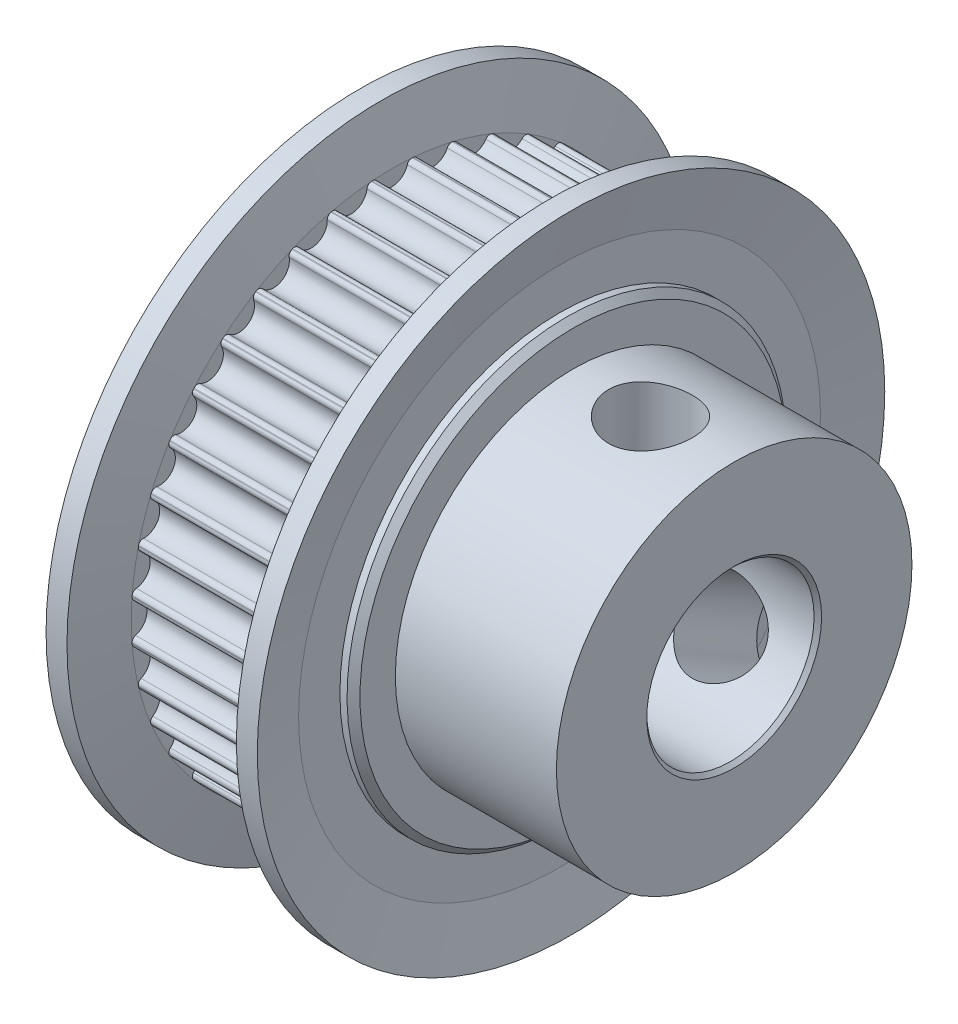
from build123d import *

# Parameters (mm, degrees)
SKETCH_20_W              = 8.35
SKETCH_20_H              = 8.5
REVOLVE_5_ANGLE          = 360
CUT_EXTRUDE_START        = 1.65
CUT_EXTRUDE_1_DEPTH      = 7
PATTERN_CIRCULAR_1_COUNT = 40
SKETCH_6_R               = 4
CUT_EXTRUDE_2_DEPTH      = 19
CHAMFER_1_SIZE           = 0.18
SKETCH_25_R              = 2
CUT_EXTRUDE_3_DEPTH      = 16
PATTERN_CIRCULAR_2_COUNT = 2
PATTERN_CIRCULAR_2_ANGLE = 120


with BuildPart() as part:
    # Sketch 3 → Revolve 1 (revolve)
    with BuildSketch(Plane.XY):
        Polygon((0, 0), (0, 10.19), (0.31, 10.5), (1.65, 10.5), (1.65, 12.475), (8.65, 12.475), (8.65, 10.5), (9.99, 10.5), (10.3, 10.19), (10.3, 0), align=None)
    revolve(axis=Axis((10.3, 0, 0), (-1, 0, 0)))

    # Sketch 20 → Revolve 5 (revolve, symmetric)
    with BuildSketch(Plane.XY) as revolve_5_sk:
        with Locations((13.825, 4.25)):
            Rectangle(SKETCH_20_W, SKETCH_20_H)
    revolve(axis=Axis((18, 0, 0), (-1, 0, 0)), revolution_arc=REVOLVE_5_ANGLE / 2)
    revolve(revolve_5_sk.sketch, axis=Axis((18, 0, 0), (1, 0, 0)), revolution_arc=REVOLVE_5_ANGLE / 2)

    # Sketch 4 → Cut-Extrude 1 (cut)
    with BuildSketch(Plane(origin=(0, 0, 0), x_dir=(0, 0, -1), z_dir=(1, 0, 0)).offset(CUT_EXTRUDE_START)):
        with BuildLine():
            ThreePointArc((0.960818708, 12.437944059), (0.811492896, 12.397249789), (0.72176343, 12.271143307))
            ThreePointArc((0.72176343, 12.271143307), (0, 11.725), (-0.72176343, 12.271143307))
            ThreePointArc((-0.72176343, 12.271143307), (-0.811492896, 12.397249789), (-0.960818708, 12.437944059))
            ThreePointArc((-0.960818708, 12.437944059), (0, 12.475), (0.960818708, 12.437944059))
        make_face()
    cut_extrude_1 = extrude(amount=CUT_EXTRUDE_1_DEPTH, mode=Mode.SUBTRACT)

    # Pattern Circular 1: Cut-Extrude 1 ×40 about axis
    pattern_circular_1_axis = Axis((0, 0, 0), (1, 0, 0))
    for i in range(1, PATTERN_CIRCULAR_1_COUNT):
        add(cut_extrude_1.rotate(pattern_circular_1_axis, i * 360 / PATTERN_CIRCULAR_1_COUNT), mode=Mode.SUBTRACT)

    # Sketch 5 → Revolve 2 (revolve)
    with BuildSketch(Plane.XY):
        Polygon((1.1, 15), (1.65, 12.475), (1.65, 10.5), (0.65, 10.5), (0.65, 12.475), (0.1, 15), align=None)
        Polygon((9.65, 10.5), (8.65, 10.5), (8.65, 12.475), (9.2, 15), (10.2, 15), (9.65, 12.475), align=None)
    revolve(axis=Axis((0, 0, 0), (1, 0, 0)))

    # Sketch 6 → Cut-Extrude 2 (cut, through all)
    with BuildSketch(Plane(origin=(0, 0, 0), x_dir=(0, 0, -1), z_dir=(1, 0, 0))):
        Circle(SKETCH_6_R)
    extrude(amount=CUT_EXTRUDE_2_DEPTH, mode=Mode.SUBTRACT)

    # Chamfer 1
    chamfer_1_edges = [part.edges().sort_by_distance(p)[0] for p in [
        (0, 0, 4),
        (18, 0, 4),
    ]]
    chamfer(chamfer_1_edges, length=CHAMFER_1_SIZE)

    # Sketch 25 → Cut-Extrude 3 (cut, through all)
    with BuildSketch(Plane(origin=(0, 0, 0), x_dir=(1, 0, 0), z_dir=(0, 1, 0))):
        with Locations((14, 0)):
            Circle(SKETCH_25_R)
    cut_extrude_3 = extrude(amount=CUT_EXTRUDE_3_DEPTH, mode=Mode.SUBTRACT)

    # Pattern Circular 2: Cut-Extrude 3 ×2 about axis
    pattern_circular_2_axis = Axis((18, 0, 0), (-1, 0, 0))
    for i in range(1, PATTERN_CIRCULAR_2_COUNT):
        add(cut_extrude_3.rotate(pattern_circular_2_axis, i * PATTERN_CIRCULAR_2_ANGLE / (PATTERN_CIRCULAR_2_COUNT - 1)), mode=Mode.SUBTRACT)


solid = part.part
